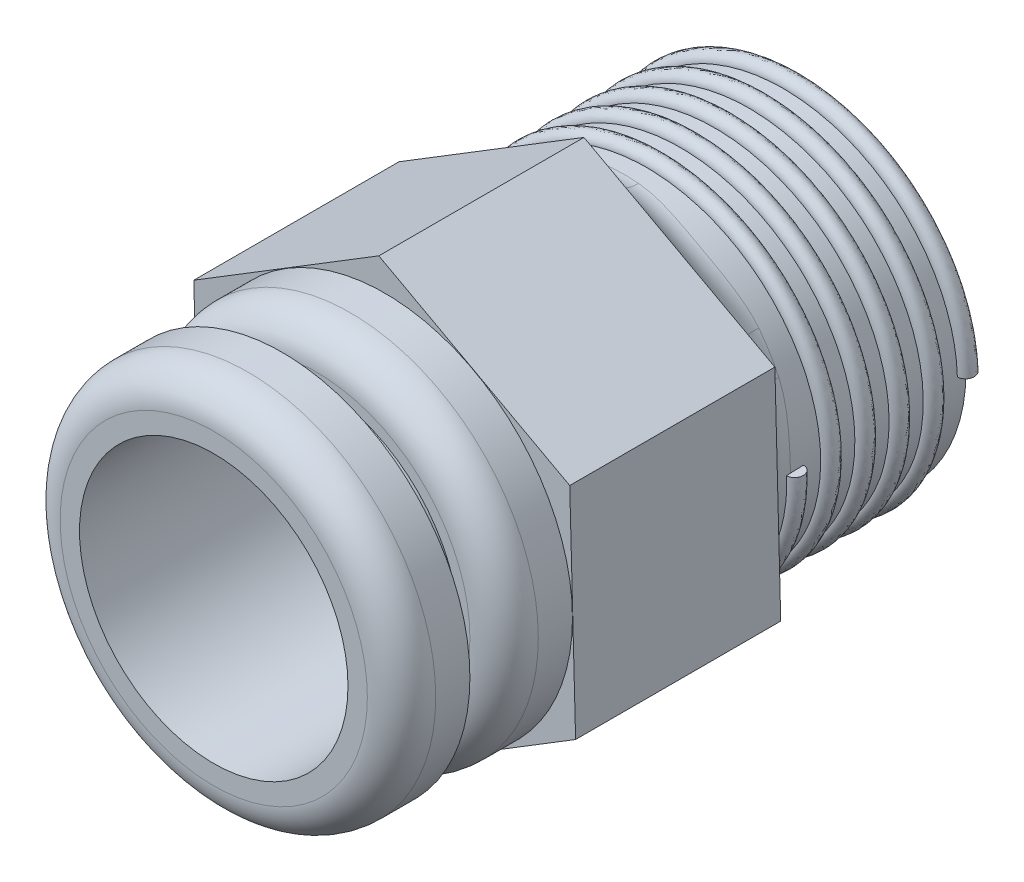
from build123d import *

# Parameters (mm, degrees)
SKETCH1_R           = 5
BOSS_EXTRUDE1_DEPTH = 6
BOSS_EXTRUDE2_DEPTH = 6
FILLET1_R           = 1
SKETCH3_R           = 5.492448039
BOSS_EXTRUDE3_DEPTH = 2
FILLET2_R           = 1
SKETCH4_R           = 4.184498631
SKETCH4_R_2         = 3.926580887
BOSS_EXTRUDE4_DEPTH = 1
SKETCH5_R           = 5.492448039
SKETCH5_R_2         = 3.926580887
BOSS_EXTRUDE5_DEPTH = 2
FILLET3_R           = 1
SKETCH6_R           = 3.926580887
CUT_EXTRUDE1_DEPTH  = 32
SWEEP2_PITCH        = 1
SWEEP2_HEIGHT       = 5
SWEEP2_RADIUS       = 5
SKETCH13_R          = 0.25


with BuildPart() as part:
    # Sketch1 → Boss-Extrude1 (new body)
    with BuildSketch(Plane.XY):
        Circle(SKETCH1_R)
    extrude(amount=BOSS_EXTRUDE1_DEPTH)

    # Sketch2 → Boss-Extrude2 (add)
    with BuildSketch(Plane.XY.offset(6)):
        Polygon((5.583852968, -3.025544475), (5.412124859, 3.322986283), (-0.171728108, 6.348530758), (-5.583852968, 3.025544475), (-5.412124859, -3.322986283), (0.171728108, -6.348530758), align=None)
    extrude(amount=BOSS_EXTRUDE2_DEPTH)

    # Fillet1
    fillet1_edges = [part.edges().sort_by_distance(p)[0] for p in [
        (-5, 0, 6),
    ]]
    fillet(fillet1_edges, radius=FILLET1_R)

    # Sketch3 → Boss-Extrude3 (add)
    with BuildSketch(Plane.XY.offset(12)):
        Circle(SKETCH3_R)
    extrude(amount=BOSS_EXTRUDE3_DEPTH)

    # Fillet2
    fillet2_edges = [part.edges().sort_by_distance(p)[0] for p in [
        (-5.492448039, 0, 14),
    ]]
    fillet(fillet2_edges, radius=FILLET2_R)

    # Sketch4 → Boss-Extrude4 (add)
    with BuildSketch(Plane.XY.offset(14)):
        Circle(SKETCH4_R)
        Circle(SKETCH4_R_2, mode=Mode.SUBTRACT)
    extrude(amount=BOSS_EXTRUDE4_DEPTH)

    # Sketch5 → Boss-Extrude5 (add)
    with BuildSketch(Plane.XY.offset(15)):
        Circle(SKETCH5_R)
        Circle(SKETCH5_R_2, mode=Mode.SUBTRACT)
    extrude(amount=BOSS_EXTRUDE5_DEPTH)

    # Fillet3
    fillet3_edges = [part.edges().sort_by_distance(p)[0] for p in [
        (-5.492448039, 0, 17),
    ]]
    fillet(fillet3_edges, radius=FILLET3_R)

    # Sketch6 → Cut-Extrude1 (cut)
    with BuildSketch(Plane.XY.offset(14)):
        Circle(SKETCH6_R)
    extrude(amount=-CUT_EXTRUDE1_DEPTH, mode=Mode.SUBTRACT)

    # Sweep2: sweep along a helix
    with BuildLine() as sweep2_path:
        Helix(SWEEP2_PITCH, SWEEP2_HEIGHT, SWEEP2_RADIUS, center=(0, 0, 0), direction=(0, 0, 1))
    # Sketch13 → Sweep2 (sweep)
    with BuildSketch(Plane(origin=(5, 0, 0), x_dir=(1, 0, 0), z_dir=(6.665504752377052e-15, 0.9994937787313604, 0.03181487509493854))):
        Circle(SKETCH13_R)
    sweep(path=sweep2_path.line, is_frenet=True)


solid = part.part
